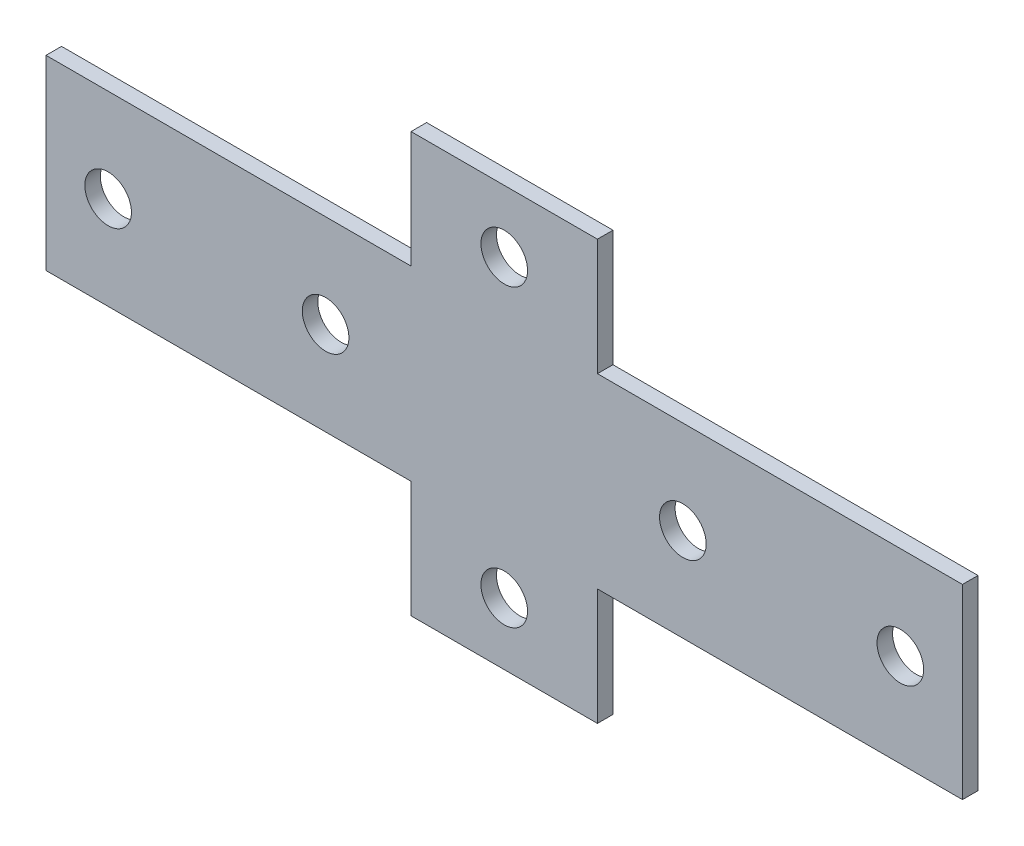
from build123d import *

# Parameters (mm, degrees)
SKETCH_1_R      = 4.5
EXTRUDE_1_DEPTH = 3


with BuildPart() as part:
    # Эскиз1 → Бобышка-Вытянуть1 (new body)
    with BuildSketch(Plane.XY):
        Polygon((18, -18), (88.5, -18), (88.5, 18), (18, 18), (18, 40.5), (-18, 40.5), (-18, 18), (-88.5, 18), (-88.5, -18), (-18, -18), (-18, -40.5), (18, -40.5), align=None)
        with Locations((0, 28.5)):
            Circle(SKETCH_1_R, mode=Mode.SUBTRACT)
        with Locations((0, -28.5)):
            Circle(SKETCH_1_R, mode=Mode.SUBTRACT)
        with Locations((-76.5, 0)):
            Circle(SKETCH_1_R, mode=Mode.SUBTRACT)
        with Locations((-34.5, 0)):
            Circle(SKETCH_1_R, mode=Mode.SUBTRACT)
        with Locations(Location((34.5, 0, 0), (0, 0, 180))):  # turned: the seam where the file's is
            Circle(SKETCH_1_R, mode=Mode.SUBTRACT)
        with Locations(Location((76.5, 0, 0), (0, 0, 180))):  # turned: the seam where the file's is
            Circle(SKETCH_1_R, mode=Mode.SUBTRACT)
    extrude(amount=EXTRUDE_1_DEPTH)


solid = part.part
